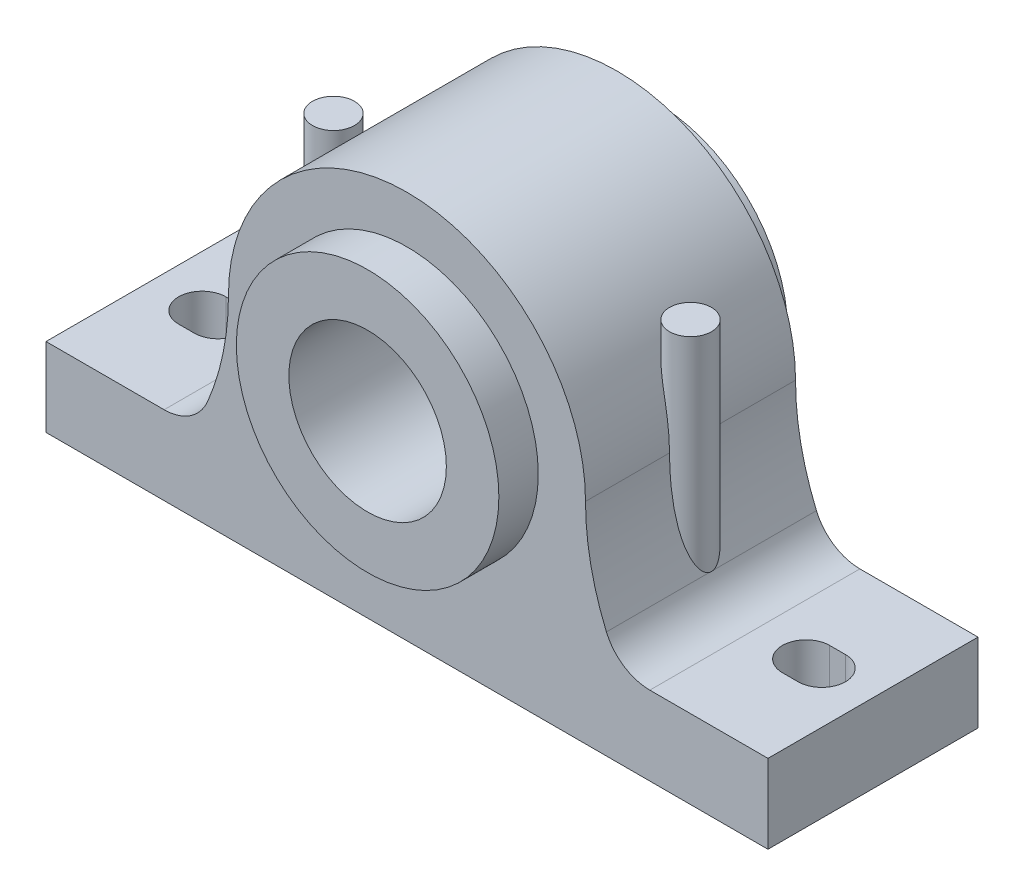
from build123d import *

# Parameters (mm, degrees)
SKETCH1_R                = 30
BOSS_EXTRUDE1_DEPTH      = 40
SKETCH2_R                = 50
SKETCH2_R_2              = 30
BOSS_EXTRUDE2_DEPTH      = 55
CUT_EXTRUDE1_DEPTH       = 110
SKETCH5_R                = 8
BOSS_EXTRUDE3_DEPTH      = 40
BOSS_EXTRUDE3_DEPTH_BACK = 60


with BuildPart() as part:
    # Sketch1 → Boss-Extrude1 (new body, symmetric)
    with BuildSketch(Plane.XY):
        with BuildLine():
            Line((137.5, -80), (-137.5, -80))
            Line((-137.5, -80), (-137.5, -50))
            Line((-137.5, -50), (-92.5, -50))
            ThreePointArc((-92.5, -50), (-82.586036695, -47.018171653), (-75.961854895, -39.062156056))
            ThreePointArc((-75.961854895, -39.062156056), (-70.010718453, -19.932656428), (-68, 0))
            ThreePointArc((-68, 0), (0, 68), (68, 0))
            ThreePointArc((68, 0), (70.010718453, -19.932656428), (75.961854895, -39.062156056))
            ThreePointArc((75.961854895, -39.062156056), (82.586036695, -47.018171653), (92.5, -50))
            Line((92.5, -50), (137.5, -50))
            Line((137.5, -50), (137.5, -80))
        make_face()
        Circle(SKETCH1_R, mode=Mode.SUBTRACT)
    extrude(amount=BOSS_EXTRUDE1_DEPTH, both=True)

    # Sketch2 → Boss-Extrude2 (add, symmetric)
    with BuildSketch(Plane.XY):
        Circle(SKETCH2_R)
        Circle(SKETCH2_R_2, mode=Mode.SUBTRACT)
    extrude(amount=BOSS_EXTRUDE2_DEPTH, both=True)

    # Sketch3 → Cut-Extrude1 (cut)
    with BuildSketch(Plane(origin=(0, 0, 0), x_dir=(1, 0, 0), z_dir=(0, 1, 0))):
        with BuildLine():
            Line((-118, 9), (-112, 9))
            ThreePointArc((-112, 9), (-103, 0), (-112, -9))
            Line((-112, -9), (-118, -9))
            ThreePointArc((-118, -9), (-127, 0), (-118, 9))
        make_face()
        with BuildLine():
            Line((118, 9), (112, 9))
            ThreePointArc((112, 9), (103, 0), (112, -9))
            Line((112, -9), (118, -9))
            ThreePointArc((118, -9), (127, 0), (118, 9))
        make_face()
    extrude(amount=-CUT_EXTRUDE1_DEPTH, mode=Mode.SUBTRACT)

    # Sketch5 → Boss-Extrude3 (add, two sides)
    with BuildSketch(Plane(origin=(0, 0, 0), x_dir=(1, 0, 0), z_dir=(0, 1, 0))) as boss_extrude3_sk:
        with Locations((-68, 0)):
            Circle(SKETCH5_R)
        with Locations((68, 0)):
            Circle(SKETCH5_R)
    extrude(amount=BOSS_EXTRUDE3_DEPTH)
    extrude(boss_extrude3_sk.sketch, amount=-BOSS_EXTRUDE3_DEPTH_BACK)


solid = part.part
